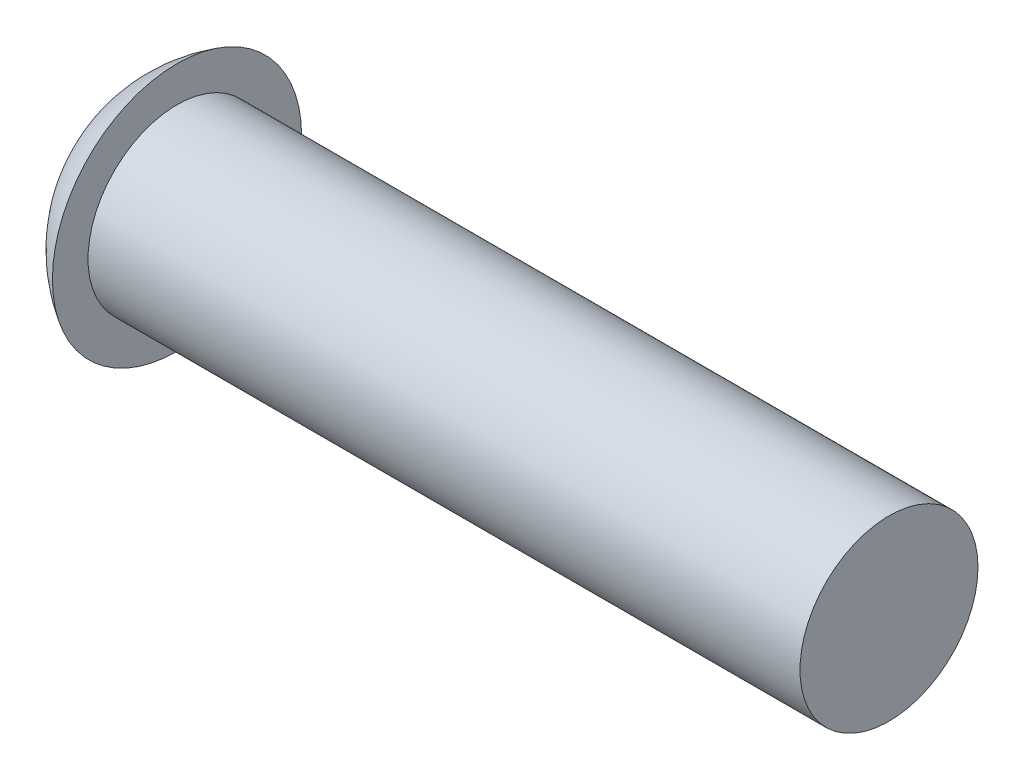
from build123d import *


with BuildPart() as part:
    # Sketch2 → Revolve1 (revolve)
    with BuildSketch(Plane(origin=(0, 0, 0), x_dir=(1, 0, 0), z_dir=(0, 1, 0))):
        with BuildLine():
            Line((110, 0), (110, 12.5))
            Line((110, 12.5), (10, 12.5))
            Line((10, 12.5), (10, 17.5))
            ThreePointArc((10, 17.5), (2.676311176, 10.077822185), (0, 0))
            Line((0, 0), (110, 0))
        make_face()
    revolve(axis=Axis((110, 0, 0), (-1, 0, 0)))


solid = part.part
